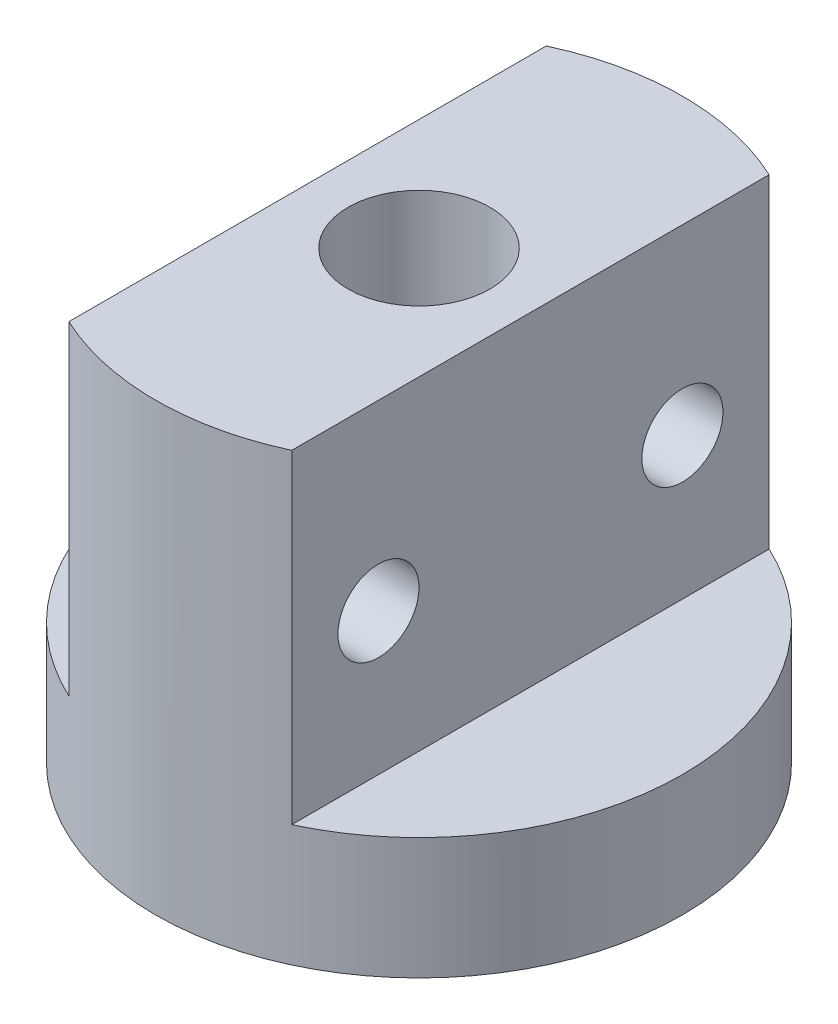
from build123d import *

# Parameters (mm, degrees)
SKETCH1_R               = 13
BOSS_EXTRUDE1_DEPTH     = 22
SKETCH2_R               = 7
CUT_EXTRUDE1_DEPTH      = 5
SKETCH3_W               = 8.709717948
SKETCH3_H               = 17.861131539
SKETCH3_W_2             = 9.032332804
SKETCH3_H_2             = 17.802474292
CUT_EXTRUDE2_DEPTH      = 14
CUT_EXTRUDE2_DEPTH_BACK = 14
SKETCH4_R               = 2
CUT_EXTRUDE3_DEPTH      = 14
CUT_EXTRUDE3_DEPTH_BACK = 14
CUT_EXTRUDE4_START      = 22
SKETCH5_R               = 3.5
CUT_EXTRUDE4_DEPTH      = 5
SKETCH6_R               = 1.5
CUT_EXTRUDE5_DEPTH      = 23


with BuildPart() as part:
    # Sketch1 → Boss-Extrude1 (new body)
    with BuildSketch(Plane(origin=(0, 0, 0), x_dir=(1, 0, 0), z_dir=(0, 1, 0))):
        Circle(SKETCH1_R)
    extrude(amount=BOSS_EXTRUDE1_DEPTH)

    # Sketch2 → Cut-Extrude1 (cut)
    with BuildSketch(Plane(origin=(0, 0, 0), x_dir=(1, 0, 0), z_dir=(0, 1, 0))):
        Circle(SKETCH2_R)
    extrude(amount=CUT_EXTRUDE1_DEPTH, mode=Mode.SUBTRACT)

    # Sketch3 → Cut-Extrude2 (cut, two sides)
    with BuildSketch(Plane.XY) as cut_extrude2_sk:
        with Locations((9.854858974, 14.93056577)):
            Rectangle(SKETCH3_W, SKETCH3_H)
        with Locations((-10.016166402, 14.901237146)):
            Rectangle(SKETCH3_W_2, SKETCH3_H_2)
    extrude(amount=CUT_EXTRUDE2_DEPTH, mode=Mode.SUBTRACT)
    extrude(cut_extrude2_sk.sketch, amount=-CUT_EXTRUDE2_DEPTH_BACK, mode=Mode.SUBTRACT)

    # Sketch4 → Cut-Extrude3 (cut, two sides)
    with BuildSketch(Plane(origin=(0, 0, 0), x_dir=(0, 0, -1), z_dir=(1, 0, 0))) as cut_extrude3_sk:
        with Locations((-7.5, 13)):
            Circle(SKETCH4_R)
        with Locations((7.5, 13)):
            Circle(SKETCH4_R)
    extrude(amount=CUT_EXTRUDE3_DEPTH, mode=Mode.SUBTRACT)
    extrude(cut_extrude3_sk.sketch, amount=-CUT_EXTRUDE3_DEPTH_BACK, mode=Mode.SUBTRACT)

    # Sketch5 → Cut-Extrude4 (cut)
    with BuildSketch(Plane(origin=(0, 0, 0), x_dir=(1, 0, 0), z_dir=(0, 1, 0)).offset(CUT_EXTRUDE4_START)):
        Circle(SKETCH5_R)
    extrude(amount=-CUT_EXTRUDE4_DEPTH, mode=Mode.SUBTRACT)

    # Sketch6 → Cut-Extrude5 (cut, through all)
    with BuildSketch(Plane(origin=(0, 0, 0), x_dir=(1, 0, 0), z_dir=(0, 1, 0))):
        Circle(SKETCH6_R)
    extrude(amount=CUT_EXTRUDE5_DEPTH, mode=Mode.SUBTRACT)


solid = part.part
